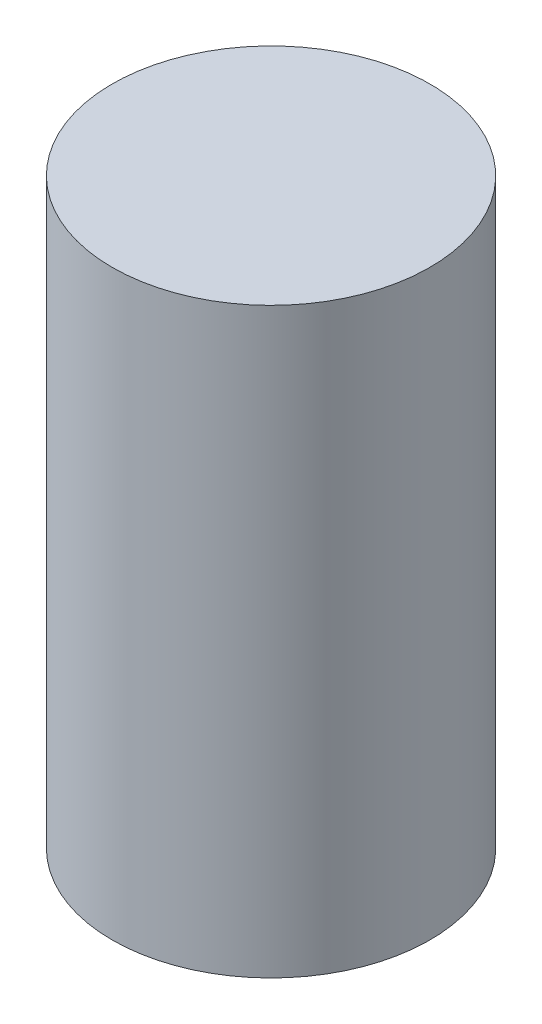
from build123d import *

# Parameters (mm, degrees)
SKETCH1_R           = 9
BOSS_EXTRUDE1_DEPTH = 33


with BuildPart() as part:
    # Sketch1 → Boss-Extrude1 (new body)
    with BuildSketch(Plane(origin=(0, 0, 0), x_dir=(1, 0, 0), z_dir=(0, 1, 0))):
        Circle(SKETCH1_R)
    extrude(amount=BOSS_EXTRUDE1_DEPTH)


solid = part.part
